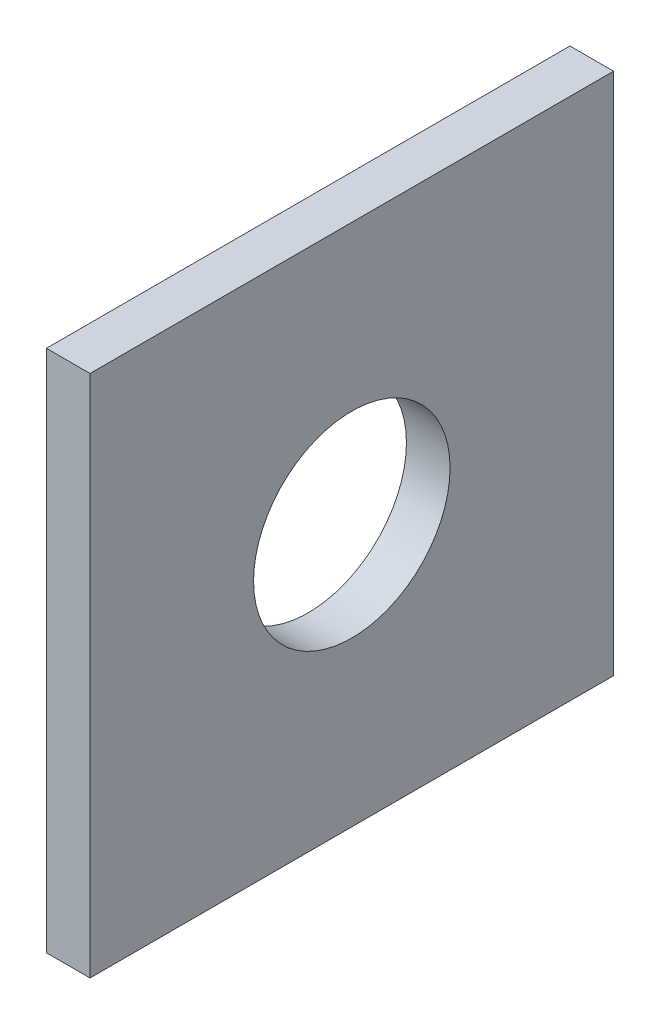
from build123d import *

# Parameters (mm, degrees)
SKETCH3_W                   = 3.175
SKETCH3_H                   = 38.1
APERTURE_PLATE_F_DEPTH      = 19.05
APERTURE_PLATE_F_DEPTH_BACK = 19.05
APERTURE_F_REACH            = 5.175
SKETCH6_R                   = 7.1501


with BuildPart() as part:
    # Sketch3 → APERTURE_PLATE_F (new body, two sides)
    with BuildSketch(Plane(origin=(0, 0, 0), x_dir=(1, 0, 0), z_dir=(0, 1, 0))) as aperture_plate_f_sk:
        with Locations((-72.7075, 0)):
            Rectangle(SKETCH3_W, SKETCH3_H)
    extrude(amount=APERTURE_PLATE_F_DEPTH)
    extrude(aperture_plate_f_sk.sketch, amount=-APERTURE_PLATE_F_DEPTH_BACK)

    # Sketch6 → APERTURE_F (cut, up to next)
    with BuildSketch(Plane(origin=(-71.12, 0, 0), x_dir=(0, 0, -1), z_dir=(1, 0, 0)), mode=Mode.PRIVATE) as aperture_f_sk1:
        Circle(SKETCH6_R)
    aperture_f_tool1 = extrude(aperture_f_sk1.sketch, amount=-APERTURE_F_REACH, mode=Mode.PRIVATE) & part.part
    add(aperture_f_tool1.solids().sort_by_distance((-71.12, 0, 0))[0], mode=Mode.SUBTRACT)


solid = part.part
